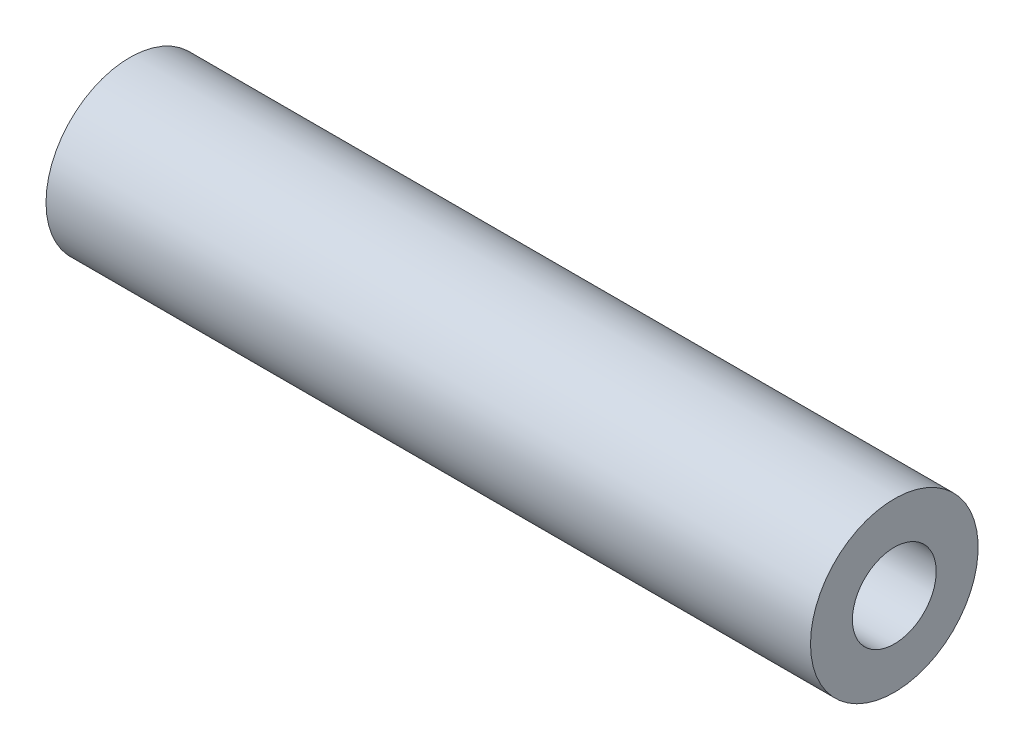
from build123d import *

# Parameters (mm, degrees)
SKETCH1_W             = 22.8
SKETCH1_H             = 2.5
M3X0_5_TAPPED_HOLE1_D = 2.5


with BuildPart() as part:
    # Sketch1 → Revolve1 (revolve)
    with BuildSketch(Plane.XY):
        with Locations((11.4, 1.25)):
            Rectangle(SKETCH1_W, SKETCH1_H)
    revolve(axis=Axis((-10.305290241, 0, 0), (1, 0, 0)))

    # M3x0.5 Tapped Hole1 (through all)
    with Locations(Plane.ZY):
        with Locations((0, 0)):
            Hole(M3X0_5_TAPPED_HOLE1_D / 2)


solid = part.part
